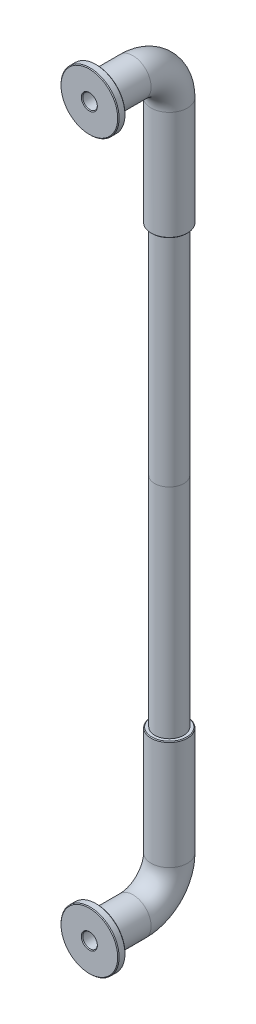
from build123d import *

# Parameters (mm, degrees)
SCHIZZO1_R                   = 2.5
SCHIZZO1_R_2                 = 1
SMUSSO1_SIZE                 = 0.1
SCHIZZO3_R                   = 2
SCHIZZO3_R_2                 = 1
ESTRUSIONE_ESTRUSIONE1_DEPTH = 30
SCHIZZO4_R                   = 2
SCHIZZO4_R_2                 = 1
ESTRUSIONE_ESTRUSIONE2_DEPTH = 30
SCHIZZO5_R                   = 2.5
SCHIZZO5_R_2                 = 1
SMUSSO2_SIZE                 = 0.1
SCHIZZO7_R                   = 4
SCHIZZO7_R_2                 = 1
ESTRUSIONE_ESTRUSIONE3_DEPTH = 1
SCHIZZO8_R                   = 4
SCHIZZO8_R_2                 = 1
ESTRUSIONE_ESTRUSIONE4_DEPTH = 1
SMUSSO3_SIZE                 = 0.1
SMUSSO4_SIZE                 = 0.1


with BuildPart() as part:
    # Sweep1: sweep along a path in Schizzo2
    with BuildLine(Plane(origin=(0, 0, 0), x_dir=(0, 0, -1), z_dir=(1, 0, 0))) as sweep1_path:
        Line((0, 0), (5, 0))
        ThreePointArc((5, 0), (8.535533906, -1.464466094), (10, -5))
        Line((10, -5), (10, -20))
    # Schizzo1 → Sweep1 (sweep)
    with BuildSketch(Plane.XY):
        Circle(SCHIZZO1_R)
        Circle(SCHIZZO1_R_2, mode=Mode.SUBTRACT)
    sweep(path=sweep1_path.line)

    # Smusso1
    smusso1_edges = [part.edges().sort_by_distance(p)[0] for p in [
        (-2.5, -20, -10),
    ]]
    chamfer(smusso1_edges, length=SMUSSO1_SIZE)

    # Schizzo3 → Estrusione-Estrusione1 (add)
    with BuildSketch(Plane.XZ.offset(20)):
        with Locations((0, -10)):
            Circle(SCHIZZO3_R)
        with Locations((0, -10)):
            Circle(SCHIZZO3_R_2, mode=Mode.SUBTRACT)
    extrude(amount=ESTRUSIONE_ESTRUSIONE1_DEPTH)

    # Schizzo7 → Estrusione-Estrusione3 (add)
    with BuildSketch(Plane.XY):
        Circle(SCHIZZO7_R)
        Circle(SCHIZZO7_R_2, mode=Mode.SUBTRACT)
    extrude(amount=ESTRUSIONE_ESTRUSIONE3_DEPTH)

    # Smusso4
    smusso4_edges = [part.edges().sort_by_distance(p)[0] for p in [
        (-4, 0, 1),
        (-4, 0, 0),
        (-1, 0, 1),
    ]]
    chamfer(smusso4_edges, length=SMUSSO4_SIZE)


with BuildPart() as body_2:
    # Schizzo4 → Estrusione-Estrusione2 (new body)
    with BuildSketch(Plane.XZ.offset(50)):
        with Locations((0, -10)):
            Circle(SCHIZZO4_R)
        with Locations((0, -10)):
            Circle(SCHIZZO4_R_2, mode=Mode.SUBTRACT)
    extrude(amount=ESTRUSIONE_ESTRUSIONE2_DEPTH)

    # Sweep2: sweep along a path in Schizzo6
    with BuildLine(Plane(origin=(0, 0, 0), x_dir=(0, 0, -1), z_dir=(1, 0, 0))) as sweep2_path:
        Line((10, -80), (10, -95))
        ThreePointArc((10, -95), (8.535533906, -98.535533906), (5, -100))
        Line((5, -100), (0, -100))
    # Schizzo5 → Sweep2 (sweep)
    with BuildSketch(Plane.XZ.offset(80)):
        with Locations((0, -10)):
            Circle(SCHIZZO5_R)
        with Locations((0, -10)):
            Circle(SCHIZZO5_R_2, mode=Mode.SUBTRACT)
    sweep(path=sweep2_path.line)

    # Smusso2
    smusso2_edges = [body_2.edges().sort_by_distance(p)[0] for p in [
        (-2.5, -80, -10),
    ]]
    chamfer(smusso2_edges, length=SMUSSO2_SIZE)

    # Schizzo8 → Estrusione-Estrusione4 (add)
    with BuildSketch(Plane.XY):
        with Locations((0, -100)):
            Circle(SCHIZZO8_R)
        with Locations((0, -100)):
            Circle(SCHIZZO8_R_2, mode=Mode.SUBTRACT)
    extrude(amount=ESTRUSIONE_ESTRUSIONE4_DEPTH)

    # Smusso3
    smusso3_edges = [body_2.edges().sort_by_distance(p)[0] for p in [
        (-4, -100, 1),
        (-4, -100, 0),
        (-1, -100, 1),
    ]]
    chamfer(smusso3_edges, length=SMUSSO3_SIZE)


solid = Compound([part.part, body_2.part])
